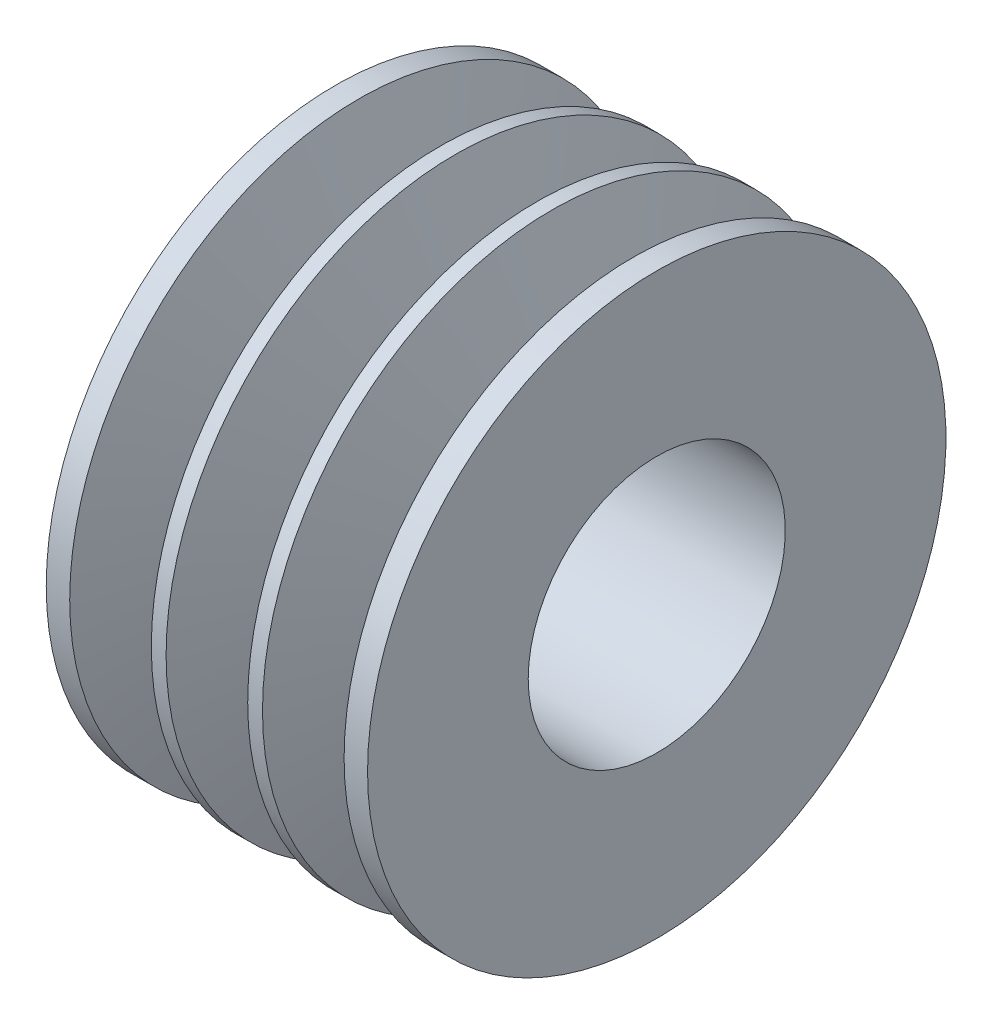
from build123d import *


with BuildPart() as part:
    # Skizze1 → Rotation2 (revolve)
    with BuildSketch(Plane.XY, mode=Mode.PRIVATE) as rotation2_sk:
        Polygon((45.099637471, 45.974649946), (95.099637471, 45.974649946), (95.099637471, 70.974649946), (91.449637471, 70.974649946), (87.230554067, 57.174649946), (82.968720876, 57.174649946), (78.749637471, 70.974649946), (76.449637471, 70.974649946), (72.230554067, 57.174649946), (70.099637471, 57.174649946), (67.968720876, 57.174649946), (63.749637471, 70.974649946), (61.449637471, 70.974649946), (57.230554067, 57.174649946), (52.968720876, 57.174649946), (48.749637471, 70.974649946), (45.099637471, 70.974649946), align=None)
    revolve(rotation2_sk.sketch.rotate(Axis((24.821753872, 25.974649946, 0), (1, 0, 0)), 90), axis=Axis((24.821753872, 25.974649946, 0), (1, 0, 0)))  # turned: the seam where the file's is


solid = part.part
